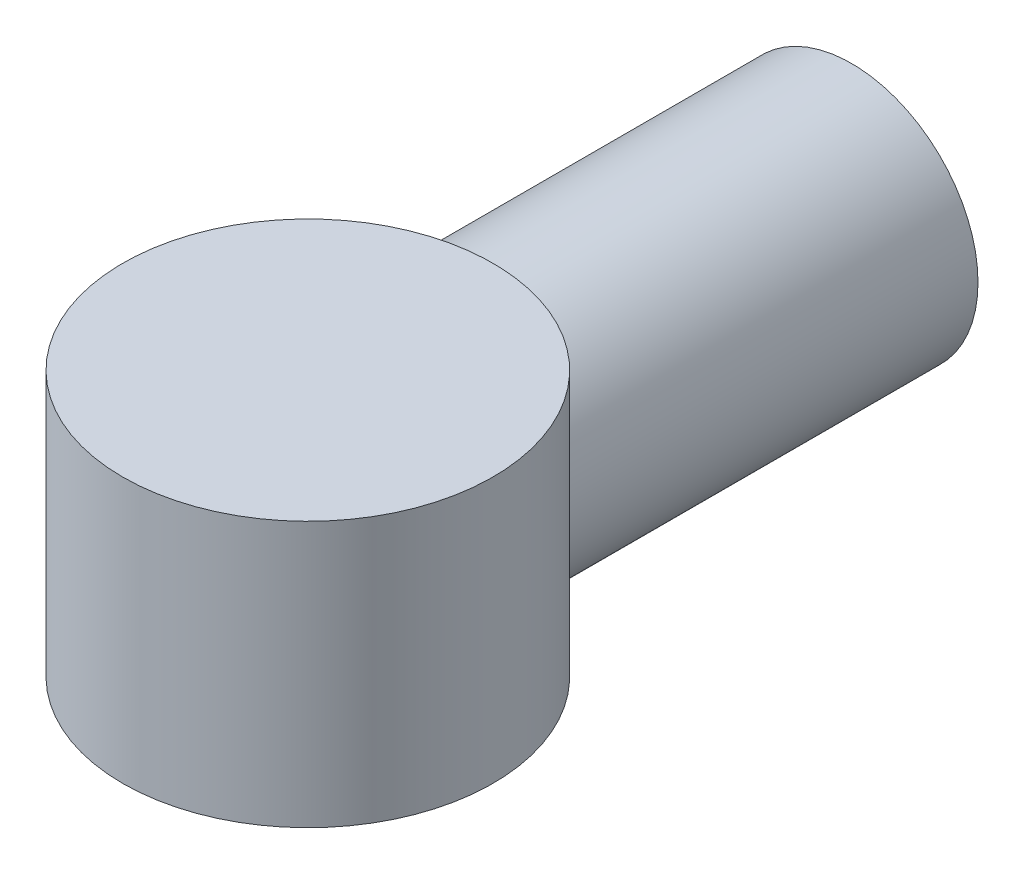
from build123d import *

# Parameters (mm, degrees)
SKETCH1_R           = 23.8
SKETCH1_R_2         = 19
BOSS_EXTRUDE1_DEPTH = 80
SKETCH5_R           = 34.886960806
BOSS_EXTRUDE2_DEPTH = 25


with BuildPart() as part:
    # Sketch1 → Boss-Extrude1 (new body)
    with BuildSketch(Plane.XY):
        Circle(SKETCH1_R)
        Circle(SKETCH1_R_2, mode=Mode.SUBTRACT)
    extrude(amount=BOSS_EXTRUDE1_DEPTH)

    # Sketch5 → Boss-Extrude2 (add, symmetric)
    with BuildSketch(Plane(origin=(0, 0, 0), x_dir=(1, 0, 0), z_dir=(0, 1, 0))):
        with Locations((0, -102.473472637)):
            Circle(SKETCH5_R)
    extrude(amount=BOSS_EXTRUDE2_DEPTH, both=True)


solid = part.part
